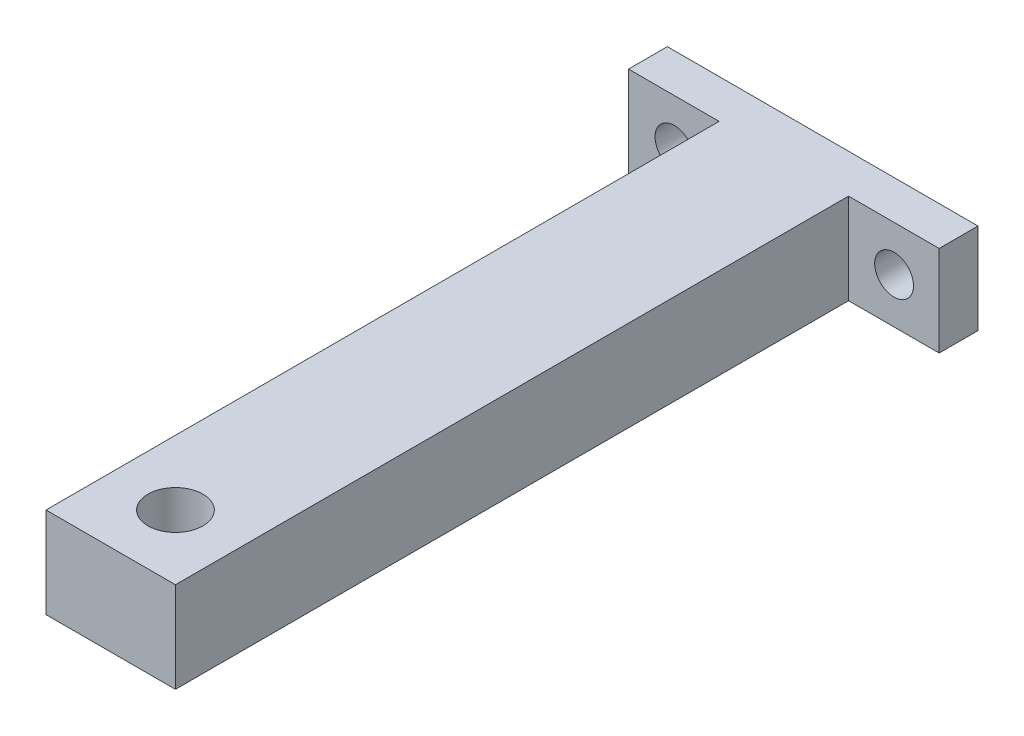
from build123d import *

# Parameters (mm, degrees)
SKETCH_1_W          = 24
SKETCH_1_H          = 7
EXTRUDE_2_DEPTH     = 3
SKETCH_3_W          = 10
SKETCH_3_H          = 7
EXTRUDE_4_DEPTH     = 52
SKETCH_5_R          = 2.125
CUT_EXTRUDE_1_DEPTH = 7
SKETCH_6_R          = 1.5
CUT_EXTRUDE_2_DEPTH = 3
SKETCH_7_R          = 1.5
CUT_EXTRUDE_3_DEPTH = 3


with BuildPart() as part:
    # Эскиз1 → Бобышка-Вытянуть2 (new body)
    with BuildSketch(Plane.XY):
        Rectangle(SKETCH_1_W, SKETCH_1_H)
    extrude(amount=EXTRUDE_2_DEPTH)

    # Эскиз3 → Бобышка-Вытянуть4 (add)
    with BuildSketch(Plane.XY.offset(3)):
        Rectangle(SKETCH_3_W, SKETCH_3_H)
    extrude(amount=EXTRUDE_4_DEPTH)

    # Эскиз5 → Вырез-Вытянуть1 (cut)
    with BuildSketch(Plane(origin=(0, -3.5, 0), x_dir=(-1, 0, 0), z_dir=(0, -1, 0))):
        with Locations((0, -50)):
            Circle(SKETCH_5_R)
    extrude(amount=-CUT_EXTRUDE_1_DEPTH, mode=Mode.SUBTRACT)

    # Эскиз6 → Вырез-Вытянуть2 (cut)
    with BuildSketch(Plane.XY.offset(3)):
        with Locations((8.516484568, 0)):
            Circle(SKETCH_6_R)
    extrude(amount=-CUT_EXTRUDE_2_DEPTH, mode=Mode.SUBTRACT)

    # Эскиз7 → Вырез-Вытянуть3 (cut)
    with BuildSketch(Plane.XY.offset(3)):
        with Locations((-8.452342131, 0)):
            Circle(SKETCH_7_R)
    extrude(amount=-CUT_EXTRUDE_3_DEPTH, mode=Mode.SUBTRACT)


solid = part.part
